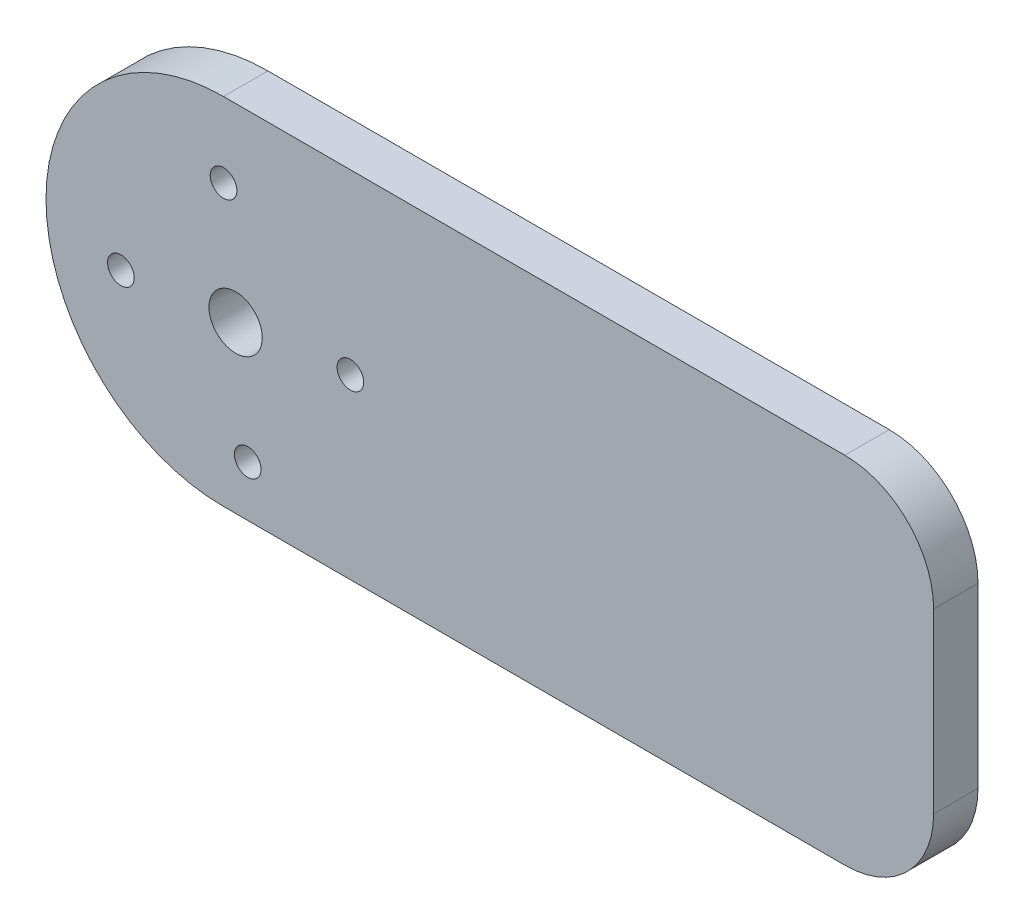
from build123d import *

# Parameters (mm, degrees)
SKETCH1_R           = 1.5
BOSS_EXTRUDE1_DEPTH = 5
SKETCH2_R           = 3
CUT_EXTRUDE1_DEPTH  = 10
FILLET1_R           = 10


with BuildPart() as part:
    # Sketch1 → Boss-Extrude1 (new body)
    with BuildSketch(Plane.XY):
        with BuildLine():
            Line((0, 20), (80, 20))
            Line((80, 20), (80, -20))
            Line((80, -20), (0, -20))
            ThreePointArc((0, -20), (-20, 0), (0, 20))
        make_face()
        with Locations((0, 11.564458964)):
            Circle(SKETCH1_R, mode=Mode.SUBTRACT)
        with Locations((14.292070839, 0)):
            Circle(SKETCH1_R, mode=Mode.SUBTRACT)
        with Locations((2.727611874, -14.292070839)):
            Circle(SKETCH1_R, mode=Mode.SUBTRACT)
        with Locations((-11.564458964, -2.727611874)):
            Circle(SKETCH1_R, mode=Mode.SUBTRACT)
    extrude(amount=BOSS_EXTRUDE1_DEPTH)

    # Sketch2 → Cut-Extrude1 (cut)
    with BuildSketch(Plane(origin=(0, 0, 0), x_dir=(-1, 0, 0), z_dir=(0, 0, -1))):
        with Locations((-1.363805937, -1.363805937)):
            Circle(SKETCH2_R)
    extrude(amount=-CUT_EXTRUDE1_DEPTH, mode=Mode.SUBTRACT)

    # Fillet1
    fillet1_edges = [part.edges().sort_by_distance(p)[0] for p in [
        (80, 20, 2.5),
        (80, -20, 2.5),
    ]]
    fillet(fillet1_edges, radius=FILLET1_R)


solid = part.part
